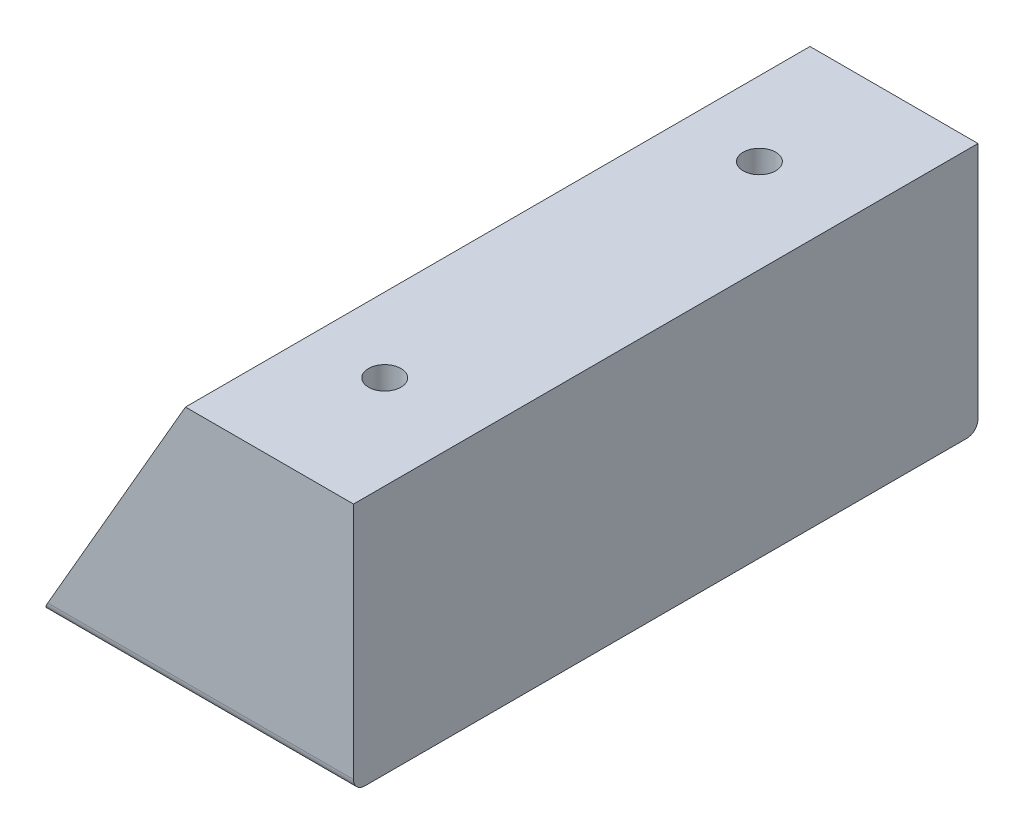
from build123d import *

# Parameters (mm, degrees)
BOSS_EXTRUDE1_DEPTH = 50
SKETCH3_R           = 2.6
CUT_EXTRUDE2_DEPTH  = 15
FILLET2_R           = 1.8
FILLET3_R           = 1.8


with BuildPart() as part:
    # Sketch1 → Boss-Extrude1 (new body, symmetric)
    with BuildSketch(Plane.XY):
        Polygon((0, 0), (50, 0), (50, 40), (23.094010768, 40), align=None)
    extrude(amount=BOSS_EXTRUDE1_DEPTH, both=True)

    # Sketch3 → Cut-Extrude2 (cut)
    with BuildSketch(Plane(origin=(0, 40, 0), x_dir=(1, 0, 0), z_dir=(0, 1, 0))):
        with Locations((35, 30)):
            Circle(SKETCH3_R)
        with Locations((35, -30)):
            Circle(SKETCH3_R)
    extrude(amount=-CUT_EXTRUDE2_DEPTH, mode=Mode.SUBTRACT)

    # Fillet2
    fillet2_edges = [part.edges().sort_by_distance(p)[0] for p in [
        (25, 0, 50),
    ]]
    fillet(fillet2_edges, radius=FILLET2_R)

    # Fillet3
    fillet3_edges = [part.edges().sort_by_distance(p)[0] for p in [
        (25, 0, -50),
    ]]
    fillet(fillet3_edges, radius=FILLET3_R)


solid = part.part
